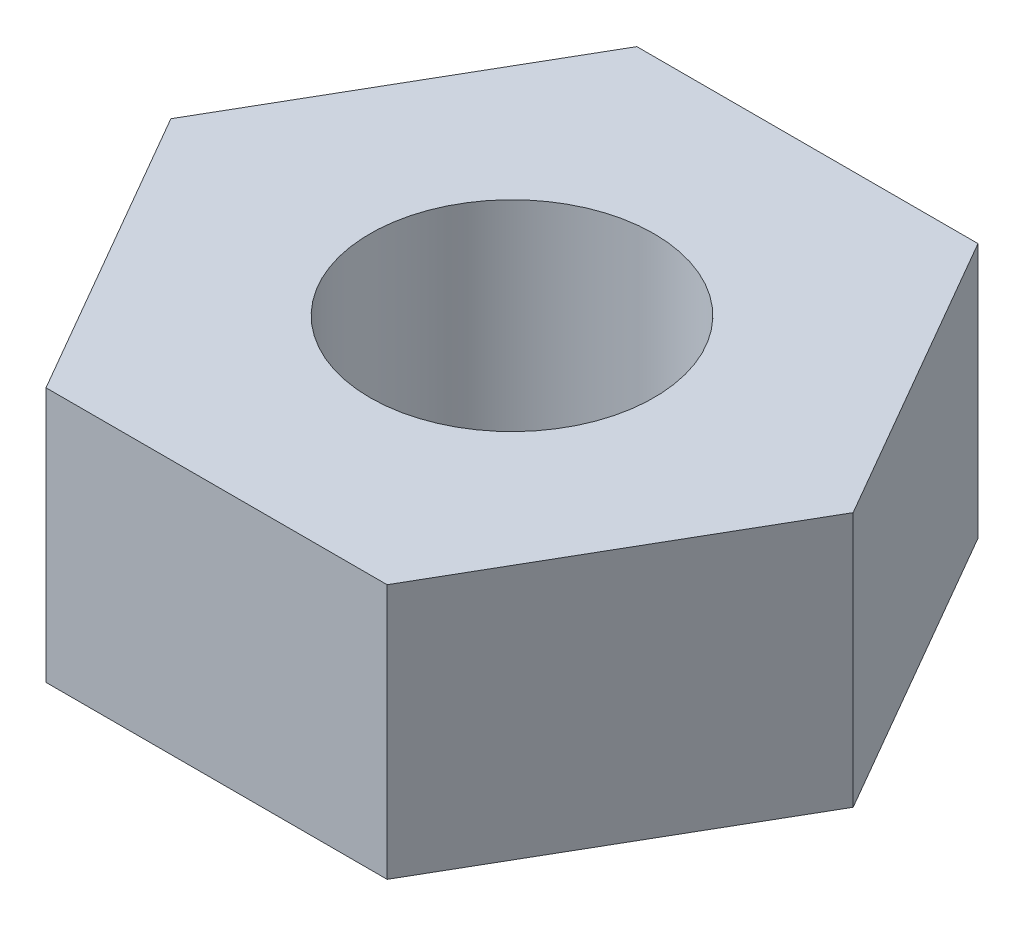
from build123d import *

# Parameters (mm, degrees)
BOSS_EXTRUDE1_DEPTH = 1.68
SKETCH2_R           = 0.935
CUT_EXTRUDE1_DEPTH  = 2.68


with BuildPart() as part:
    # Sketch1 → Boss-Extrude1 (new body)
    with BuildSketch(Plane(origin=(0, 0, 0), x_dir=(1, 0, 0), z_dir=(0, 1, 0))):
        Polygon((1.122946274, -1.945), (2.245892547, 0), (1.122946274, 1.945), (-1.122946274, 1.945), (-2.245892547, 0), (-1.122946274, -1.945), align=None)
    extrude(amount=BOSS_EXTRUDE1_DEPTH)

    # Sketch2 → Cut-Extrude1 (cut, through all)
    with BuildSketch(Plane(origin=(0, 1.68, 0), x_dir=(1, 0, 0), z_dir=(0, 1, 0))):
        Circle(SKETCH2_R)
    extrude(amount=-CUT_EXTRUDE1_DEPTH, mode=Mode.SUBTRACT)


solid = part.part
